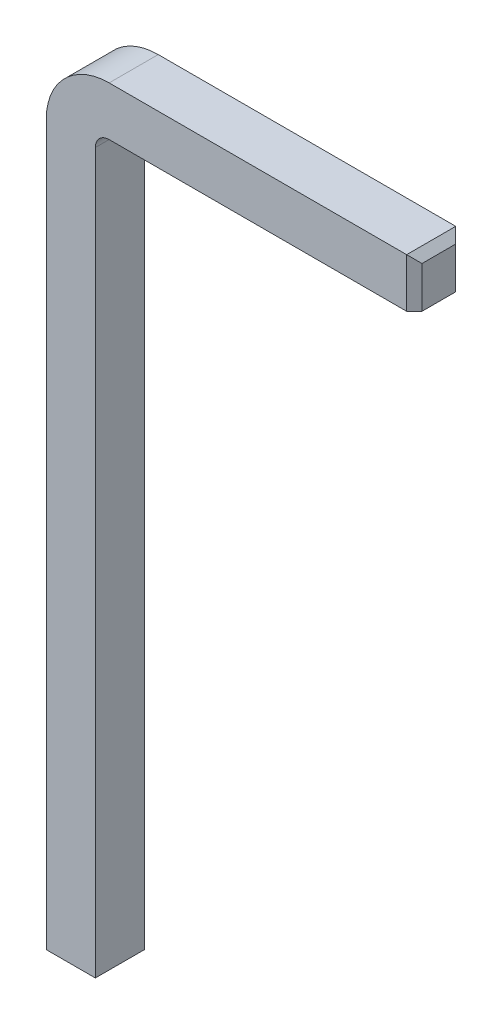
from build123d import *

# Parameters (mm, degrees)
SKETCH_1_W     = 0.64
SKETCH_1_H     = 0.64
CHAMFER_1_SIZE = 0.1


with BuildPart() as part:
    # По траектории1: sweep along a path in Эскиз2
    with BuildLine(Plane.XY) as sweep_1_path:
        Line((0, 0), (0, 9.48))
        ThreePointArc((0, 9.48), (0.146446609, 9.833553391), (0.5, 9.98))
        Line((0.5, 9.98), (4.48, 9.98))
    # Эскиз1 → По траектории1 (sweep)
    with BuildSketch(Plane(origin=(0, 0, 0), x_dir=(1, 0, 0), z_dir=(0, 1, 0))):
        Rectangle(SKETCH_1_W, SKETCH_1_H)
    sweep(path=sweep_1_path.line)

    # Фаска1
    chamfer_1_edges = [part.edges().sort_by_distance(p)[0] for p in [
        (4.48, 9.98, 0.32),
        (4.48, 10.3, 0),
        (4.48, 9.98, -0.32),
        (0, 0, 0.32),
        (-0.32, 0, 0),
        (0, 0, -0.32),
        (0.32, 0, 0),
    ]]
    chamfer(chamfer_1_edges, length=CHAMFER_1_SIZE)


solid = part.part
